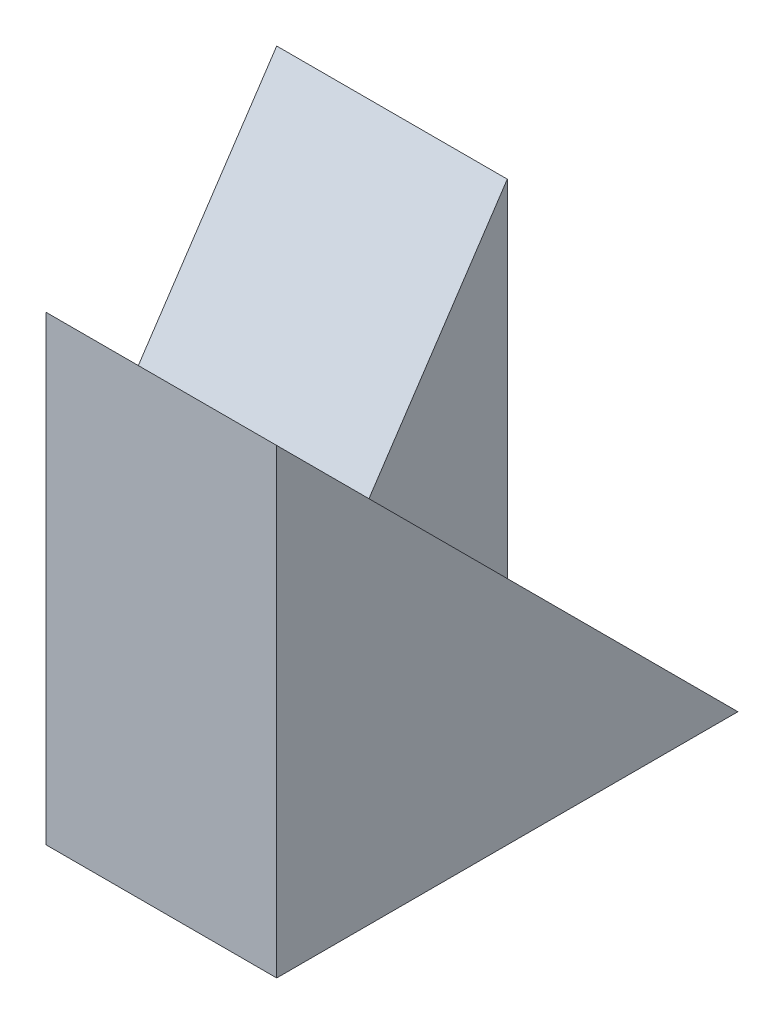
from build123d import *

# Parameters (mm, degrees)
SKETCH1_W           = 4
SKETCH1_H           = 4
BOSS_EXTRUDE1_DEPTH = 2
SKETCH2_W           = 2
SKETCH2_H           = 3
BOSS_EXTRUDE2_DEPTH = 2
CUT_EXTRUDE2_DEPTH  = 2
CUT_EXTRUDE3_DEPTH  = 2


with BuildPart() as part:
    # Sketch1 → Boss-Extrude1 (new body)
    with BuildSketch(Plane(origin=(0, 0, 0), x_dir=(0, 0, -1), z_dir=(1, 0, 0))):
        with Locations((2, 2)):
            Rectangle(SKETCH1_W, SKETCH1_H)
    extrude(amount=BOSS_EXTRUDE1_DEPTH)

    # Sketch2 → Boss-Extrude2 (add)
    with BuildSketch(Plane.ZY):
        with Locations((-3, 1.5)):
            Rectangle(SKETCH2_W, SKETCH2_H)
    extrude(amount=BOSS_EXTRUDE2_DEPTH)

    # Sketch3 → Cut-Extrude2 (cut)
    with BuildSketch(Plane(origin=(2, 0, 0), x_dir=(0, 0, -1), z_dir=(1, 0, 0))):
        Polygon((0, 4), (4, 0), (4, 4), align=None)
    extrude(amount=-CUT_EXTRUDE2_DEPTH, mode=Mode.SUBTRACT)

    # Sketch4 → Cut-Extrude3 (cut)
    with BuildSketch(Plane.ZY.offset(2)):
        Polygon((-2, 0), (-4, 3), (-2, 3), align=None)
    extrude(amount=-CUT_EXTRUDE3_DEPTH, mode=Mode.SUBTRACT)


solid = part.part
